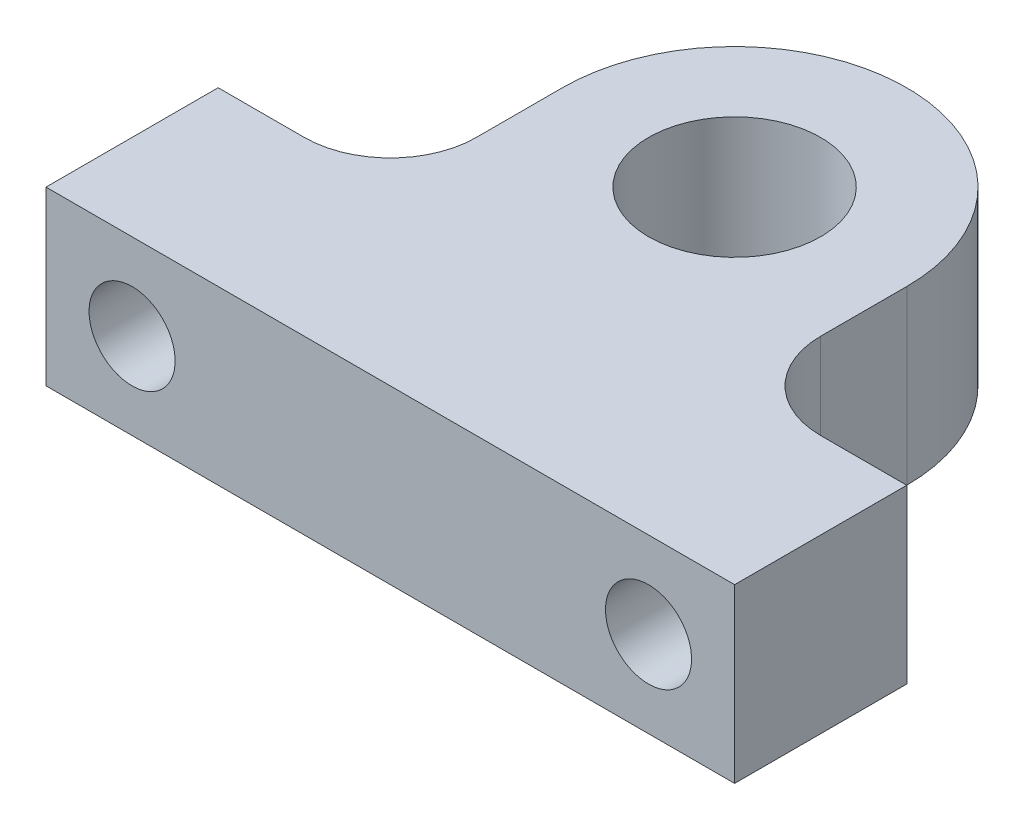
from build123d import *

# Parameters (mm, degrees)
SKETCH1_R               = 6.35
BOSS_EXTRUDE1_DEPTH     = 12.7
FILLET1_R               = 6.35
SKETCH2_R               = 3.175
CUT_EXTRUDE1_DEPTH      = 26.4
CUT_EXTRUDE1_DEPTH_BACK = 13.7


with BuildPart() as part:
    # Sketch1 → Boss-Extrude1 (new body)
    with BuildSketch(Plane(origin=(0, 0, 0), x_dir=(1, 0, 0), z_dir=(0, 1, 0))):
        with BuildLine():
            Line((-12.7, 0), (-12.7, -12.7))
            Line((-12.7, -12.7), (-25.4, -12.7))
            Line((-25.4, -12.7), (-25.4, -25.4))
            Line((-25.4, -25.4), (25.4, -25.4))
            Line((25.4, -25.4), (25.4, -12.7))
            Line((25.4, -12.7), (12.7, -12.7))
            Line((12.7, -12.7), (12.7, 0))
            ThreePointArc((12.7, 0), (0, 12.7), (-12.7, 0))
        make_face()
        Circle(SKETCH1_R, mode=Mode.SUBTRACT)
    extrude(amount=BOSS_EXTRUDE1_DEPTH)

    # Fillet1
    fillet1_edges = [part.edges().sort_by_distance(p)[0] for p in [
        (12.7, 6.35, 12.7),
        (-12.7, 6.35, 12.7),
    ]]
    fillet(fillet1_edges, radius=FILLET1_R)

    # Sketch2 → Cut-Extrude1 (cut, two sides)
    with BuildSketch(Plane(origin=(0, 0, 12.7), x_dir=(-1, 0, 0), z_dir=(0, 0, -1))) as cut_extrude1_sk:
        with Locations((19.05, 6.35)):
            Circle(SKETCH2_R)
        with Locations((-19.05, 6.35)):
            Circle(SKETCH2_R)
    extrude(amount=CUT_EXTRUDE1_DEPTH, mode=Mode.SUBTRACT)
    extrude(cut_extrude1_sk.sketch, amount=-CUT_EXTRUDE1_DEPTH_BACK, mode=Mode.SUBTRACT)


solid = part.part
